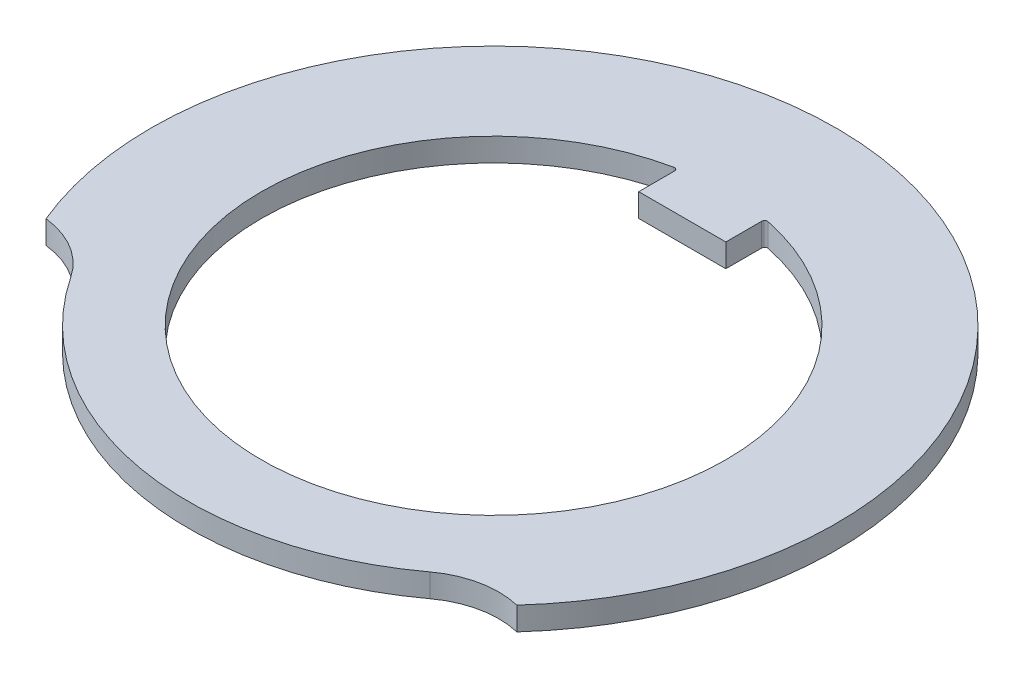
from build123d import *

# Parameters (mm, degrees)
BOSS_EXTRUDE1_DEPTH = 0.8
FILLET1_R           = 0.1


with BuildPart() as part:
    # Sketch1 → Boss-Extrude1 (new body)
    with BuildSketch(Plane(origin=(0, 0, 0), x_dir=(1, 0, 0), z_dir=(0, 1, 0))):
        with BuildLine():
            ThreePointArc((8.734573904, -7.933928328), (2.023691137, 11.625174157), (-10.901778484, -4.515664502))
            ThreePointArc((-10.901778484, -4.515664502), (-9.670610732, -4.932925102), (-8.73153967, -5.831827757))
            ThreePointArc((-8.73153967, -5.831827757), (-1.800742113, -10.344434631), (6.247243618, -8.439309639))
            ThreePointArc((6.247243618, -8.439309639), (7.434829013, -7.910611831), (8.734573904, -7.933928328))
        make_face()
        with BuildLine():
            Line((-1.5, 6.5), (1.5, 6.5))
            Line((1.5, 6.5), (1.5, 7.858116823))
            ThreePointArc((1.5, 7.858116823), (0, -8), (-1.5, 7.858116823))
            Line((-1.5, 7.858116823), (-1.5, 6.5))
        make_face(mode=Mode.SUBTRACT)
    extrude(amount=BOSS_EXTRUDE1_DEPTH)

    # Fillet1
    fillet1_edges = [part.edges().sort_by_distance(p)[0] for p in [
        (-1.5, 0.4, -7.858116823),
        (1.5, 0.4, -7.858116823),
    ]]
    fillet(fillet1_edges, radius=FILLET1_R)


solid = part.part
